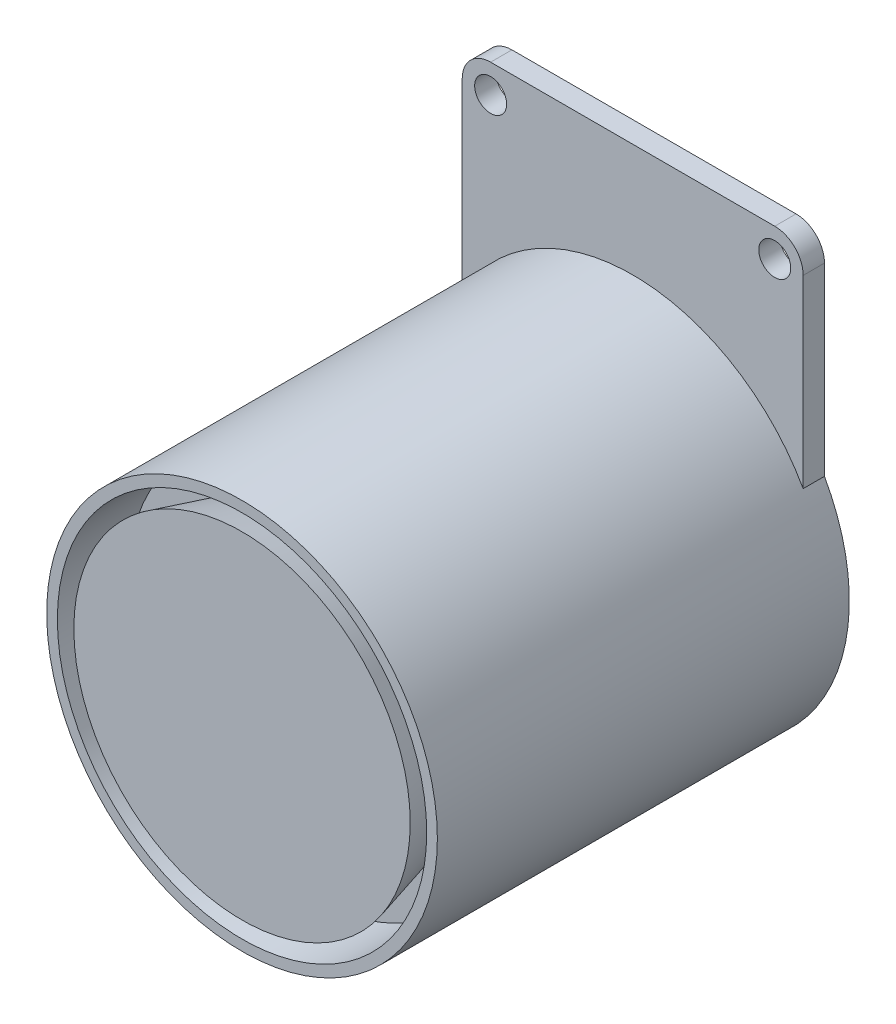
from build123d import *

# Parameters (mm, degrees)
SZKIC1_R                    = 27.5
SZKIC1_W                    = 48
SZKIC1_H                    = 30
DODANIE_WYCI_GNI_CIE1_DEPTH = 3
SZKIC2_R                    = 27.5
DODANIE_WYCI_GNI_CIE2_DEPTH = 55
SZKIC3_R                    = 26
WYTNIJ_WYCI_GNI_CIE1_DEPTH  = 10
SZKIC4_R                    = 21
DODANIE_WYCI_GNI_CIE3_DEPTH = 10
DODANIE_WYCI_GNI_CIE3_TAPER = -15
WYTNIJ_WYCI_GNI_CIE2_REACH  = 5
SZKIC5_R                    = 2.25
ZAOKR_GLENIE1_R             = 4


with BuildPart() as part:
    # Szkic1 → Dodanie-wyciągnięcie1 (new body)
    with BuildSketch(Plane.XY):
        Circle(SZKIC1_R)
        with Locations((0, 28.425721582)):
            Rectangle(SZKIC1_W, SZKIC1_H)
    extrude(amount=DODANIE_WYCI_GNI_CIE1_DEPTH)

    # Szkic2 → Dodanie-wyciągnięcie2 (add)
    with BuildSketch(Plane.XY.offset(3)):
        Circle(SZKIC2_R)
    extrude(amount=DODANIE_WYCI_GNI_CIE2_DEPTH)

    # Szkic3 → Wytnij-wyciągnięcie1 (cut)
    with BuildSketch(Plane.XY.offset(58)):
        Circle(SZKIC3_R)
    extrude(amount=-WYTNIJ_WYCI_GNI_CIE1_DEPTH, mode=Mode.SUBTRACT)

    # Szkic4 → Dodanie-wyciągnięcie3 (add)
    with BuildSketch(Plane.XY.offset(48)):
        Circle(SZKIC4_R)
    extrude(amount=DODANIE_WYCI_GNI_CIE3_DEPTH, taper=DODANIE_WYCI_GNI_CIE3_TAPER)

    # Szkic5 → Wytnij-wyciągnięcie2 (cut, up to next)
    with BuildSketch(Plane.XY.offset(3), mode=Mode.PRIVATE) as wytnij_wyci_gni_cie2_sk1:
        with Locations((-20, 39.425721582)):
            Circle(SZKIC5_R)
    wytnij_wyci_gni_cie2_tool1 = extrude(wytnij_wyci_gni_cie2_sk1.sketch, amount=-WYTNIJ_WYCI_GNI_CIE2_REACH, mode=Mode.PRIVATE) & part.part
    add(wytnij_wyci_gni_cie2_tool1.solids().sort_by_distance((-20, 39.425722, 3))[0], mode=Mode.SUBTRACT)
    # Szkic5 → Wytnij-wyciągnięcie2 (cut, up to next)
    with BuildSketch(Plane.XY.offset(3), mode=Mode.PRIVATE) as wytnij_wyci_gni_cie2_sk2:
        with Locations((20, 39.425721582)):
            Circle(SZKIC5_R)
    wytnij_wyci_gni_cie2_tool2 = extrude(wytnij_wyci_gni_cie2_sk2.sketch, amount=-WYTNIJ_WYCI_GNI_CIE2_REACH, mode=Mode.PRIVATE) & part.part
    add(wytnij_wyci_gni_cie2_tool2.solids().sort_by_distance((20, 39.425722, 3))[0], mode=Mode.SUBTRACT)

    # Zaokrąglenie1
    zaokr_glenie1_edges = [part.edges().sort_by_distance(p)[0] for p in [
        (24, 43.425721582, 1.5),
        (-24, 43.425721582, 1.5),
    ]]
    fillet(zaokr_glenie1_edges, radius=ZAOKR_GLENIE1_R)


solid = part.part
